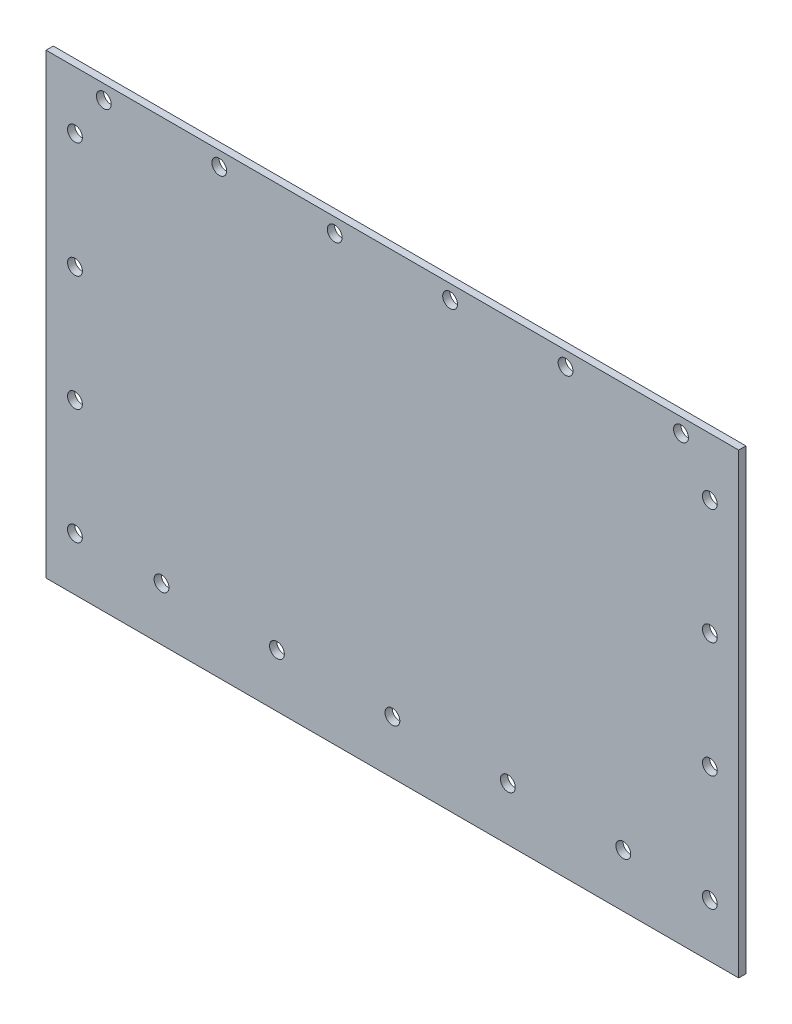
from build123d import *

# Parameters (mm, degrees)
SKETCH1_W           = 152.4
SKETCH1_H           = 100.6
SKETCH1_R           = 1.63195
BOSS_EXTRUDE1_DEPTH = 1.5875


with BuildPart() as part:
    # Sketch1 → Boss-Extrude1 (new body)
    with BuildSketch(Plane.XY):
        with Locations((76.2, -50.3)):
            Rectangle(SKETCH1_W, SKETCH1_H)
        with Locations((6.35, -88.9)):
            Circle(SKETCH1_R, mode=Mode.SUBTRACT)
        with Locations((25.4, -88.9)):
            Circle(SKETCH1_R, mode=Mode.SUBTRACT)
        with Locations((50.8, -88.9)):
            Circle(SKETCH1_R, mode=Mode.SUBTRACT)
        with Locations((6.35, -63.5)):
            Circle(SKETCH1_R, mode=Mode.SUBTRACT)
        with Locations((6.35, -38.1)):
            Circle(SKETCH1_R, mode=Mode.SUBTRACT)
        with Locations((6.35, -12.7)):
            Circle(SKETCH1_R, mode=Mode.SUBTRACT)
        with Locations((12.7, -3.175)):
            Circle(SKETCH1_R, mode=Mode.SUBTRACT)
        with Locations((38.1, -3.175)):
            Circle(SKETCH1_R, mode=Mode.SUBTRACT)
        with Locations((63.5, -3.175)):
            Circle(SKETCH1_R, mode=Mode.SUBTRACT)
        with Locations((76.2, -88.9)):
            Circle(SKETCH1_R, mode=Mode.SUBTRACT)
        with Locations((101.6, -88.9)):
            Circle(SKETCH1_R, mode=Mode.SUBTRACT)
        with Locations((127, -88.9)):
            Circle(SKETCH1_R, mode=Mode.SUBTRACT)
        with Locations((146.05, -88.9)):
            Circle(SKETCH1_R, mode=Mode.SUBTRACT)
        with Locations((88.9, -3.175)):
            Circle(SKETCH1_R, mode=Mode.SUBTRACT)
        with Locations((146.05, -63.5)):
            Circle(SKETCH1_R, mode=Mode.SUBTRACT)
        with Locations((146.05, -38.1)):
            Circle(SKETCH1_R, mode=Mode.SUBTRACT)
        with Locations((114.3, -3.175)):
            Circle(SKETCH1_R, mode=Mode.SUBTRACT)
        with Locations((139.7, -3.175)):
            Circle(SKETCH1_R, mode=Mode.SUBTRACT)
        with Locations((146.05, -12.7)):
            Circle(SKETCH1_R, mode=Mode.SUBTRACT)
    extrude(amount=BOSS_EXTRUDE1_DEPTH)


solid = part.part
